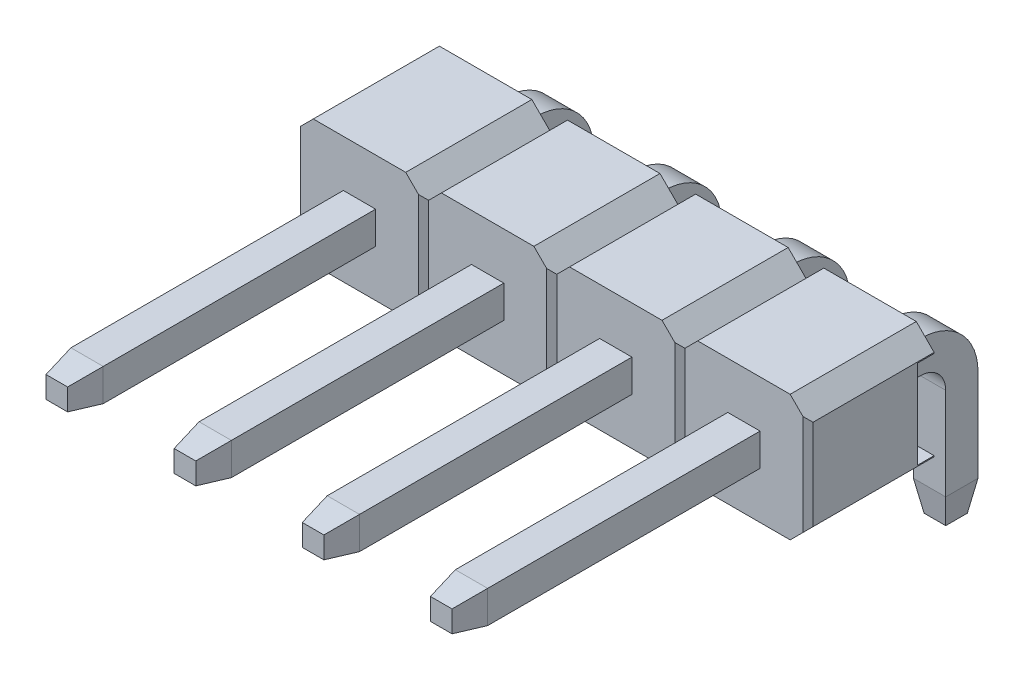
from build123d import *
from OCP.BRepFilletAPI import BRepFilletAPI_MakeChamfer

# Parameters (mm, degrees)
EXTRUDE1_DEPTH          = 1.25
CUT_EXTRUDE3_DEPTH      = 3.176671771
LPATTERN4_COUNT         = 3
LPATTERN4_PITCH         = 2.54
LPATTERN4_COUNT_DIR2    = 2
LPATTERN4_PITCH_DIR2    = 2.54
CUT_EXTRUDE1_DEPTH      = 7.591471763
CUT_EXTRUDE1_DEPTH_BACK = 7.591471763
SKETCH2_W               = 1.752893218
SKETCH2_H               = 0.33
EXTRUDE_THIN1_DEPTH     = 0.32
LPATTERN5_COUNT         = 2
LPATTERN5_PITCH         = 2.54
LPATTERN5_COUNT_DIR2    = 3
LPATTERN5_PITCH_DIR2    = 2.54
CHAMFER2_SIZE           = 0.6
CHAMFER2_SIZE2          = 0.105796188
FILLET1_R               = 0.5
FILLET2_R               = 1.14


with BuildPart() as part:
    # Sketch1 → Extrude1 (new, symmetric)
    with BuildSketch(Plane.XY):
        Polygon((-1.27, 0.896446609), (-0.916446609, 1.25), (0.916446609, 1.25), (1.27, 0.896446609), (1.27, -0.896446609), (0.916446609, -1.25), (-0.916446609, -1.25), (-1.27, -0.896446609), align=None)
    extrude1 = extrude(amount=EXTRUDE1_DEPTH, both=True)

    # Sketch4 → Cut-Extrude3 (cut, symmetric)
    with BuildSketch(Plane(origin=(0, 0, 0), x_dir=(1, 0, 0), z_dir=(0, 1, 0))):
        Polygon((-1.27, -1.15), (-1.17, -1.25), (-1.27, -1.25), align=None)
        Polygon((1.17, -1.25), (1.27, -1.15), (1.27, -1.25), align=None)
    cut_extrude3 = extrude(amount=CUT_EXTRUDE3_DEPTH, both=True, mode=Mode.SUBTRACT)

    # LPattern4: Extrude1, Cut-Extrude3 3 × 2
    with Locations(*[Vector(-1, 0, 0) * (i * LPATTERN4_PITCH) + Vector(1, 0, 0) * (j * LPATTERN4_PITCH_DIR2) for i in range(LPATTERN4_COUNT) for j in range(LPATTERN4_COUNT_DIR2) if (i, j) != (0, 0)]):
        add(extrude1)
        add(cut_extrude3, mode=Mode.SUBTRACT)

    # Sketch2 → Cut-Extrude1 (cut, two sides: drawn at the far end of the back side and taken through both)
    with BuildSketch(Plane(origin=(0, 0, 0), x_dir=(0, -1, 0), z_dir=(1, 0, 0)).offset(-CUT_EXTRUDE1_DEPTH_BACK)):
        with Locations((0, 1.085)):
            Rectangle(SKETCH2_W, SKETCH2_H)
    extrude(amount=CUT_EXTRUDE1_DEPTH + CUT_EXTRUDE1_DEPTH_BACK, mode=Mode.SUBTRACT)

    # Sketch3 → Extrude-Thin1 (add, symmetric)
    with BuildSketch(Plane(origin=(0, 0, 0), x_dir=(0, 0, -1), z_dir=(1, 0, 0))):
        Polygon((-7.25, -0.32), (2.43, -0.32), (2.43, -3.25), (3.07, -3.25), (3.07, 0.32), (-7.25, 0.32), align=None)
    extrude_thin1 = extrude(amount=EXTRUDE_THIN1_DEPTH, both=True)

    # LPattern5: Extrude-Thin1 2 × 3
    with Locations(*[Vector(1, 0, 0) * (i * LPATTERN5_PITCH) + Vector(-1, 0, 0) * (j * LPATTERN5_PITCH_DIR2) for i in range(LPATTERN5_COUNT) for j in range(LPATTERN5_COUNT_DIR2) if (i, j) != (0, 0)]):
        add(extrude_thin1)

    # Chamfer2: one chamfer whose edges measure the first distance from different faces: ONE call of the kernel's chamfer builder (chamfer() names one face for all edges)
    chamfer2_edges_1 = [part.edges().sort_by_distance(p)[0] for p in [
        (0.32, 0, 7.25),
    ]]
    chamfer2_side_1 = [part.faces().sort_by_distance(p)[0] for p in [
        (0.32, 0, 4.25),
    ]]
    chamfer2_edges_2 = [part.edges().sort_by_distance(p)[0] for p in [
        (0, -0.32, 7.25),
    ]]
    chamfer2_side_2 = [part.faces().sort_by_distance(p)[0] for p in [
        (0, -0.32, 4.25),
    ]]
    chamfer2_edges_3 = [part.edges().sort_by_distance(p)[0] for p in [
        (-0.32, 0, 7.25),
    ]]
    chamfer2_side_3 = [part.faces().sort_by_distance(p)[0] for p in [
        (-0.32, 0, 4.25),
    ]]
    chamfer2_edges_4 = [part.edges().sort_by_distance(p)[0] for p in [
        (0, 0.32, 7.25),
    ]]
    chamfer2_side_4 = [part.faces().sort_by_distance(p)[0] for p in [
        (0, 0.32, 4.25),
    ]]
    chamfer2_edges_5 = [part.edges().sort_by_distance(p)[0] for p in [
        (0.32, -3.25, -2.75),
    ]]
    chamfer2_side_5 = [part.faces().sort_by_distance(p)[0] for p in [
        (0.32, -1.029537402, -2.430462598),
    ]]
    chamfer2_edges_6 = [part.edges().sort_by_distance(p)[0] for p in [
        (0, -3.25, -3.07),
    ]]
    chamfer2_side_6 = [part.faces().sort_by_distance(p)[0] for p in [
        (0, -1.465, -3.07),
    ]]
    chamfer2_edges_7 = [part.edges().sort_by_distance(p)[0] for p in [
        (-0.32, -3.25, -2.75),
    ]]
    chamfer2_side_7 = [part.faces().sort_by_distance(p)[0] for p in [
        (-0.32, -1.029537402, -2.430462598),
    ]]
    chamfer2_edges_8 = [part.edges().sort_by_distance(p)[0] for p in [
        (0, -3.25, -2.43),
    ]]
    chamfer2_side_8 = [part.faces().sort_by_distance(p)[0] for p in [
        (0, -1.785, -2.43),
    ]]
    chamfer2_edges_9 = [part.edges().sort_by_distance(p)[0] for p in [
        (2.86, -3.25, -2.75),
    ]]
    chamfer2_side_9 = [part.faces().sort_by_distance(p)[0] for p in [
        (2.86, -1.029537402, -2.430462598),
    ]]
    chamfer2_edges_10 = [part.edges().sort_by_distance(p)[0] for p in [
        (2.54, -3.25, -3.07),
    ]]
    chamfer2_side_10 = [part.faces().sort_by_distance(p)[0] for p in [
        (2.54, -1.465, -3.07),
    ]]
    chamfer2_edges_11 = [part.edges().sort_by_distance(p)[0] for p in [
        (2.22, -3.25, -2.75),
    ]]
    chamfer2_side_11 = [part.faces().sort_by_distance(p)[0] for p in [
        (2.22, -1.029537402, -2.430462598),
    ]]
    chamfer2_edges_12 = [part.edges().sort_by_distance(p)[0] for p in [
        (2.54, -3.25, -2.43),
    ]]
    chamfer2_side_12 = [part.faces().sort_by_distance(p)[0] for p in [
        (2.54, -1.785, -2.43),
    ]]
    chamfer2_edges_13 = [part.edges().sort_by_distance(p)[0] for p in [
        (-4.76, -3.25, -2.75),
    ]]
    chamfer2_side_13 = [part.faces().sort_by_distance(p)[0] for p in [
        (-4.76, -1.029537402, -2.430462598),
    ]]
    chamfer2_edges_14 = [part.edges().sort_by_distance(p)[0] for p in [
        (-5.08, -3.25, -3.07),
    ]]
    chamfer2_side_14 = [part.faces().sort_by_distance(p)[0] for p in [
        (-5.08, -1.465, -3.07),
    ]]
    chamfer2_edges_15 = [part.edges().sort_by_distance(p)[0] for p in [
        (-5.4, -3.25, -2.75),
    ]]
    chamfer2_side_15 = [part.faces().sort_by_distance(p)[0] for p in [
        (-5.4, -1.029537402, -2.430462598),
    ]]
    chamfer2_edges_16 = [part.edges().sort_by_distance(p)[0] for p in [
        (-5.08, -3.25, -2.43),
    ]]
    chamfer2_side_16 = [part.faces().sort_by_distance(p)[0] for p in [
        (-5.08, -1.785, -2.43),
    ]]
    chamfer2_edges_17 = [part.edges().sort_by_distance(p)[0] for p in [
        (-2.22, -3.25, -2.75),
    ]]
    chamfer2_side_17 = [part.faces().sort_by_distance(p)[0] for p in [
        (-2.22, -1.029537402, -2.430462598),
    ]]
    chamfer2_edges_18 = [part.edges().sort_by_distance(p)[0] for p in [
        (-2.54, -3.25, -3.07),
    ]]
    chamfer2_side_18 = [part.faces().sort_by_distance(p)[0] for p in [
        (-2.54, -1.465, -3.07),
    ]]
    chamfer2_edges_19 = [part.edges().sort_by_distance(p)[0] for p in [
        (-2.86, -3.25, -2.75),
    ]]
    chamfer2_side_19 = [part.faces().sort_by_distance(p)[0] for p in [
        (-2.86, -1.029537402, -2.430462598),
    ]]
    chamfer2_edges_20 = [part.edges().sort_by_distance(p)[0] for p in [
        (-2.54, -3.25, -2.43),
    ]]
    chamfer2_side_20 = [part.faces().sort_by_distance(p)[0] for p in [
        (-2.54, -1.785, -2.43),
    ]]
    chamfer2_edges_21 = [part.edges().sort_by_distance(p)[0] for p in [
        (2.86, 0, 7.25),
    ]]
    chamfer2_side_21 = [part.faces().sort_by_distance(p)[0] for p in [
        (2.86, 0, 4.25),
    ]]
    chamfer2_edges_22 = [part.edges().sort_by_distance(p)[0] for p in [
        (2.54, -0.32, 7.25),
    ]]
    chamfer2_side_22 = [part.faces().sort_by_distance(p)[0] for p in [
        (2.54, -0.32, 4.25),
    ]]
    chamfer2_edges_23 = [part.edges().sort_by_distance(p)[0] for p in [
        (2.22, 0, 7.25),
    ]]
    chamfer2_side_23 = [part.faces().sort_by_distance(p)[0] for p in [
        (2.22, 0, 4.25),
    ]]
    chamfer2_edges_24 = [part.edges().sort_by_distance(p)[0] for p in [
        (2.54, 0.32, 7.25),
    ]]
    chamfer2_side_24 = [part.faces().sort_by_distance(p)[0] for p in [
        (2.54, 0.32, 4.25),
    ]]
    chamfer2_edges_25 = [part.edges().sort_by_distance(p)[0] for p in [
        (-2.22, 0, 7.25),
    ]]
    chamfer2_side_25 = [part.faces().sort_by_distance(p)[0] for p in [
        (-2.22, 0, 4.25),
    ]]
    chamfer2_edges_26 = [part.edges().sort_by_distance(p)[0] for p in [
        (-2.54, -0.32, 7.25),
    ]]
    chamfer2_side_26 = [part.faces().sort_by_distance(p)[0] for p in [
        (-2.54, -0.32, 4.25),
    ]]
    chamfer2_edges_27 = [part.edges().sort_by_distance(p)[0] for p in [
        (-2.86, 0, 7.25),
    ]]
    chamfer2_side_27 = [part.faces().sort_by_distance(p)[0] for p in [
        (-2.86, 0, 4.25),
    ]]
    chamfer2_edges_28 = [part.edges().sort_by_distance(p)[0] for p in [
        (-2.54, 0.32, 7.25),
    ]]
    chamfer2_side_28 = [part.faces().sort_by_distance(p)[0] for p in [
        (-2.54, 0.32, 4.25),
    ]]
    chamfer2_edges_29 = [part.edges().sort_by_distance(p)[0] for p in [
        (-4.76, 0, 7.25),
    ]]
    chamfer2_side_29 = [part.faces().sort_by_distance(p)[0] for p in [
        (-4.76, 0, 4.25),
    ]]
    chamfer2_edges_30 = [part.edges().sort_by_distance(p)[0] for p in [
        (-5.08, -0.32, 7.25),
    ]]
    chamfer2_side_30 = [part.faces().sort_by_distance(p)[0] for p in [
        (-5.08, -0.32, 4.25),
    ]]
    chamfer2_edges_31 = [part.edges().sort_by_distance(p)[0] for p in [
        (-5.4, 0, 7.25),
    ]]
    chamfer2_side_31 = [part.faces().sort_by_distance(p)[0] for p in [
        (-5.4, 0, 4.25),
    ]]
    chamfer2_edges_32 = [part.edges().sort_by_distance(p)[0] for p in [
        (-5.08, 0.32, 7.25),
    ]]
    chamfer2_side_32 = [part.faces().sort_by_distance(p)[0] for p in [
        (-5.08, 0.32, 4.25),
    ]]
    chamfer2 = BRepFilletAPI_MakeChamfer(part.part.solid().wrapped)
    for e in chamfer2_edges_1:
        chamfer2.Add(CHAMFER2_SIZE, CHAMFER2_SIZE2, e.wrapped, chamfer2_side_1[0].wrapped)  # the first distance lies on this face
    for e in chamfer2_edges_2:
        chamfer2.Add(CHAMFER2_SIZE, CHAMFER2_SIZE2, e.wrapped, chamfer2_side_2[0].wrapped)  # the first distance lies on this face
    for e in chamfer2_edges_3:
        chamfer2.Add(CHAMFER2_SIZE, CHAMFER2_SIZE2, e.wrapped, chamfer2_side_3[0].wrapped)  # the first distance lies on this face
    for e in chamfer2_edges_4:
        chamfer2.Add(CHAMFER2_SIZE, CHAMFER2_SIZE2, e.wrapped, chamfer2_side_4[0].wrapped)  # the first distance lies on this face
    for e in chamfer2_edges_5:
        chamfer2.Add(CHAMFER2_SIZE, CHAMFER2_SIZE2, e.wrapped, chamfer2_side_5[0].wrapped)  # the first distance lies on this face
    for e in chamfer2_edges_6:
        chamfer2.Add(CHAMFER2_SIZE, CHAMFER2_SIZE2, e.wrapped, chamfer2_side_6[0].wrapped)  # the first distance lies on this face
    for e in chamfer2_edges_7:
        chamfer2.Add(CHAMFER2_SIZE, CHAMFER2_SIZE2, e.wrapped, chamfer2_side_7[0].wrapped)  # the first distance lies on this face
    for e in chamfer2_edges_8:
        chamfer2.Add(CHAMFER2_SIZE, CHAMFER2_SIZE2, e.wrapped, chamfer2_side_8[0].wrapped)  # the first distance lies on this face
    for e in chamfer2_edges_9:
        chamfer2.Add(CHAMFER2_SIZE, CHAMFER2_SIZE2, e.wrapped, chamfer2_side_9[0].wrapped)  # the first distance lies on this face
    for e in chamfer2_edges_10:
        chamfer2.Add(CHAMFER2_SIZE, CHAMFER2_SIZE2, e.wrapped, chamfer2_side_10[0].wrapped)  # the first distance lies on this face
    for e in chamfer2_edges_11:
        chamfer2.Add(CHAMFER2_SIZE, CHAMFER2_SIZE2, e.wrapped, chamfer2_side_11[0].wrapped)  # the first distance lies on this face
    for e in chamfer2_edges_12:
        chamfer2.Add(CHAMFER2_SIZE, CHAMFER2_SIZE2, e.wrapped, chamfer2_side_12[0].wrapped)  # the first distance lies on this face
    for e in chamfer2_edges_13:
        chamfer2.Add(CHAMFER2_SIZE, CHAMFER2_SIZE2, e.wrapped, chamfer2_side_13[0].wrapped)  # the first distance lies on this face
    for e in chamfer2_edges_14:
        chamfer2.Add(CHAMFER2_SIZE, CHAMFER2_SIZE2, e.wrapped, chamfer2_side_14[0].wrapped)  # the first distance lies on this face
    for e in chamfer2_edges_15:
        chamfer2.Add(CHAMFER2_SIZE, CHAMFER2_SIZE2, e.wrapped, chamfer2_side_15[0].wrapped)  # the first distance lies on this face
    for e in chamfer2_edges_16:
        chamfer2.Add(CHAMFER2_SIZE, CHAMFER2_SIZE2, e.wrapped, chamfer2_side_16[0].wrapped)  # the first distance lies on this face
    for e in chamfer2_edges_17:
        chamfer2.Add(CHAMFER2_SIZE, CHAMFER2_SIZE2, e.wrapped, chamfer2_side_17[0].wrapped)  # the first distance lies on this face
    for e in chamfer2_edges_18:
        chamfer2.Add(CHAMFER2_SIZE, CHAMFER2_SIZE2, e.wrapped, chamfer2_side_18[0].wrapped)  # the first distance lies on this face
    for e in chamfer2_edges_19:
        chamfer2.Add(CHAMFER2_SIZE, CHAMFER2_SIZE2, e.wrapped, chamfer2_side_19[0].wrapped)  # the first distance lies on this face
    for e in chamfer2_edges_20:
        chamfer2.Add(CHAMFER2_SIZE, CHAMFER2_SIZE2, e.wrapped, chamfer2_side_20[0].wrapped)  # the first distance lies on this face
    for e in chamfer2_edges_21:
        chamfer2.Add(CHAMFER2_SIZE, CHAMFER2_SIZE2, e.wrapped, chamfer2_side_21[0].wrapped)  # the first distance lies on this face
    for e in chamfer2_edges_22:
        chamfer2.Add(CHAMFER2_SIZE, CHAMFER2_SIZE2, e.wrapped, chamfer2_side_22[0].wrapped)  # the first distance lies on this face
    for e in chamfer2_edges_23:
        chamfer2.Add(CHAMFER2_SIZE, CHAMFER2_SIZE2, e.wrapped, chamfer2_side_23[0].wrapped)  # the first distance lies on this face
    for e in chamfer2_edges_24:
        chamfer2.Add(CHAMFER2_SIZE, CHAMFER2_SIZE2, e.wrapped, chamfer2_side_24[0].wrapped)  # the first distance lies on this face
    for e in chamfer2_edges_25:
        chamfer2.Add(CHAMFER2_SIZE, CHAMFER2_SIZE2, e.wrapped, chamfer2_side_25[0].wrapped)  # the first distance lies on this face
    for e in chamfer2_edges_26:
        chamfer2.Add(CHAMFER2_SIZE, CHAMFER2_SIZE2, e.wrapped, chamfer2_side_26[0].wrapped)  # the first distance lies on this face
    for e in chamfer2_edges_27:
        chamfer2.Add(CHAMFER2_SIZE, CHAMFER2_SIZE2, e.wrapped, chamfer2_side_27[0].wrapped)  # the first distance lies on this face
    for e in chamfer2_edges_28:
        chamfer2.Add(CHAMFER2_SIZE, CHAMFER2_SIZE2, e.wrapped, chamfer2_side_28[0].wrapped)  # the first distance lies on this face
    for e in chamfer2_edges_29:
        chamfer2.Add(CHAMFER2_SIZE, CHAMFER2_SIZE2, e.wrapped, chamfer2_side_29[0].wrapped)  # the first distance lies on this face
    for e in chamfer2_edges_30:
        chamfer2.Add(CHAMFER2_SIZE, CHAMFER2_SIZE2, e.wrapped, chamfer2_side_30[0].wrapped)  # the first distance lies on this face
    for e in chamfer2_edges_31:
        chamfer2.Add(CHAMFER2_SIZE, CHAMFER2_SIZE2, e.wrapped, chamfer2_side_31[0].wrapped)  # the first distance lies on this face
    for e in chamfer2_edges_32:
        chamfer2.Add(CHAMFER2_SIZE, CHAMFER2_SIZE2, e.wrapped, chamfer2_side_32[0].wrapped)  # the first distance lies on this face
    add(Compound.cast(chamfer2.Shape()), mode=Mode.REPLACE)

    # Fillet1
    fillet1_edges = [part.edges().sort_by_distance(p)[0] for p in [
        (0, -0.32, -2.43),
        (-5.08, -0.32, -2.43),
        (-2.54, -0.32, -2.43),
        (2.54, -0.32, -2.43),
    ]]
    fillet(fillet1_edges, radius=FILLET1_R)

    # Fillet2
    fillet2_edges = [part.edges().sort_by_distance(p)[0] for p in [
        (0, 0.32, -3.07),
        (-5.08, 0.32, -3.07),
        (-2.54, 0.32, -3.07),
        (2.54, 0.32, -3.07),
    ]]
    fillet(fillet2_edges, radius=FILLET2_R)


solid = part.part
